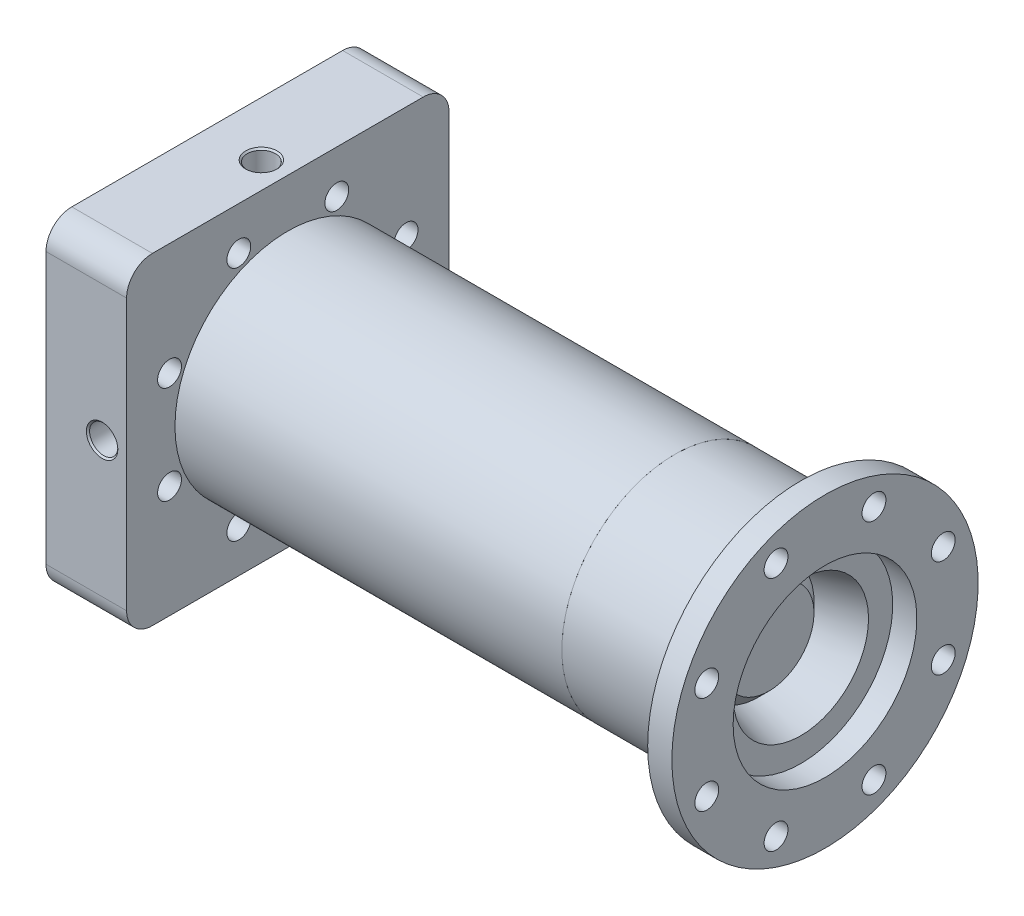
from build123d import *

# Parameters (mm, degrees)
FILLET1_R               = 1.27
CUT_EXTRUDE1_REACH      = 246.555
SKETCH2_R               = 3.81
CIRPATTERN1_COUNT       = 8
SKETCH4_R               = 63.5
BOSS_EXTRUDE1_DEPTH     = 31.75
SKETCH11_W              = 127
SKETCH11_H              = 127
SKETCH11_R              = 63.5
BOSS_EXTRUDE2_DEPTH     = 31.75
SKETCH12_R              = 24.13
CUT_EXTRUDE4_DEPTH      = 16.51
CUT_EXTRUDE5_START      = -39.450428
SKETCH13_R              = 1.9685
CUT_EXTRUDE5_DEPTH      = 39.450428
CHAMFER1_SIZE           = 4.572
FILLET2_R               = 0.889
FILLET3_R               = 0.508
CUT_EXTRUDE9_REACH      = 270.149
CUT_EXTRUDE9_END_RADIUS = 24.13
SKETCH31_R              = 1.5875
SKETCH33_R              = 44.45
SKETCH33_R_2            = 34.925
BOSS_EXTRUDE4_DEPTH     = 152.4
FILLET5_R               = 1.27
FILLET6_R               = 10.16
SKETCH39_R              = 60.325
SKETCH39_R_2            = 36.195
BOSS_EXTRUDE6_DEPTH     = 9.525
SKETCH40_R              = 4.699
CUT_EXTRUDE13_DEPTH     = 251.487228873
CIRPATTERN3_COUNT       = 8
SKETCH44_R              = 1.7653


with BuildPart() as part:
    # Chamber Revolve → Revolve1 (revolve)
    with BuildSketch(Plane.XY, mode=Mode.PRIVATE) as revolve1_sk:
        with BuildLine():
            Line((227.4696953, 63.5), (227.4696953, 26.67))
            Line((227.4696953, 26.67), (191.916500941, 17.143550283))
            ThreePointArc((191.916500941, 17.143550283), (190.601700192, 17.143550283), (189.463049342, 17.800950658))
            Line((189.463049342, 17.800950658), (173.736, 33.528))
            Line((173.736, 33.528), (0, 33.528))
            Line((0, 33.528), (0, 42.164))
            Line((0, 42.164), (3.8608, 42.164))
            Line((3.8608, 42.164), (3.8608, 48.2346))
            Line((3.8608, 48.2346), (0, 48.2346))
            Line((0, 48.2346), (0, 63.5))
            Line((0, 63.5), (10.16, 63.5))
            Line((10.16, 63.5), (10.16, 47.244))
            Line((10.16, 47.244), (24.13, 47.244))
            Line((24.13, 47.244), (24.13, 63.5))
            Line((24.13, 63.5), (227.4696953, 63.5))
        make_face()
    revolve(revolve1_sk.sketch.rotate(Axis((0, 0, 0), (1, 0, 0)), 90), axis=Axis((0, 0, 0), (1, 0, 0)))

    # Fillet1
    fillet1_edges = [part.edges().sort_by_distance(p)[0] for p in [
        (24.13, 0, -47.244),
        (10.16, 0, -47.244),
    ]]
    fillet(fillet1_edges, radius=FILLET1_R)

    # Sketch2 → Cut-Extrude1 (cut, up to next)
    with BuildSketch(Plane.ZY, mode=Mode.PRIVATE) as cut_extrude1_sk1:
        with Locations((-21.773156568, 52.565049882)):
            Circle(SKETCH2_R)
    cut_extrude1_tool1 = extrude(cut_extrude1_sk1.sketch, amount=-CUT_EXTRUDE1_REACH, mode=Mode.PRIVATE) & part.part
    cut_extrude1 = cut_extrude1_tool1.solids().sort_by_distance((0, 52.56505, -21.773157))[0]
    add(cut_extrude1, mode=Mode.SUBTRACT)

    # CirPattern1: Cut-Extrude1 ×8 about axis
    cirpattern1_axis = Axis((0, 0, 0), (1, 0, 0))
    for i in range(1, CIRPATTERN1_COUNT):
        add(cut_extrude1.rotate(cirpattern1_axis, i * 360 / CIRPATTERN1_COUNT), mode=Mode.SUBTRACT)

    # Fillet2
    fillet2_edges = [part.edges().sort_by_distance(p)[0] for p in [
        (3.8608, 0, -42.164),
        (3.8608, 0, -48.2346),
    ]]
    fillet(fillet2_edges, radius=FILLET2_R)


with BuildPart() as body_2:
    # Sketch4 → Boss-Extrude1 (new body)
    with BuildSketch(Plane.ZY):
        Circle(SKETCH4_R)
    extrude(amount=BOSS_EXTRUDE1_DEPTH)


with BuildPart() as boss_extrude2_tool:
    # Sketch11 → Boss-Extrude2 (new body)
    with BuildSketch(Plane.ZY.offset(31.75)):
        Rectangle(SKETCH11_W, SKETCH11_H)
        Circle(SKETCH11_R, mode=Mode.SUBTRACT)
    extrude(amount=-BOSS_EXTRUDE2_DEPTH)


with BuildPart() as body_2_1:
    add(body_2.part)


with BuildPart() as body_2_2:
    # Boss-Extrude2: joined with boss_extrude2_tool
    add(body_2_1.part.fuse(boss_extrude2_tool.part, tol=0.00001))


with BuildPart() as boss_extrude2_kept_piece:
    # of the separate pieces the step leaves, the one the design keeps (boss_extrude2_pieces_kept)
    add(body_2_2.part.solids().sort_by_distance((-31.75, -63.5, 63.5))[0])

    # Sketch12 → Cut-Extrude4 (cut)
    with BuildSketch(Plane(origin=(0, 0, 0), x_dir=(0, 0, -1), z_dir=(1, 0, 0))):
        Circle(SKETCH12_R)
    extrude(amount=-CUT_EXTRUDE4_DEPTH, mode=Mode.SUBTRACT)

    # Sketch13 → Cut-Extrude5 (cut)
    with BuildSketch(Plane.XY.offset(63.5).offset(CUT_EXTRUDE5_START)):
        with Locations((-9.652, 0)):
            Circle(SKETCH13_R)
    cut_extrude5 = extrude(amount=CUT_EXTRUDE5_DEPTH, mode=Mode.SUBTRACT)

    # Chamfer1
    chamfer1_edges = [boss_extrude2_kept_piece.edges().sort_by_distance(p)[0] for p in [
        (0, 0, 24.13),
    ]]
    chamfer(chamfer1_edges, length=CHAMFER1_SIZE)

    # Sketch20 → 7_16 _0.4375_ Diameter Hole1 (revolve, cut)
    with BuildSketch(Plane(origin=(-9.652, 0, 63.5), x_dir=(0, -1, 0), z_dir=(1, 0, 0))):
        Polygon((0, 0), (0, 22.388531814), (5.55625, 19.05), (5.55625, 0.635), (6.19125, 0), align=None)
    f_7_16_0_4375_diameter_hole1 = revolve(axis=Axis((-9.652, 0, 69.85), (0, 0, -1)), mode=Mode.SUBTRACT)

    # Mirror1: Cut-Extrude5, 7_16 _0.4375_ Diameter Hole1 across plane
    add(cut_extrude5.mirror(Plane.XY), mode=Mode.SUBTRACT)
    add(f_7_16_0_4375_diameter_hole1.mirror(Plane.XY), mode=Mode.SUBTRACT)

    # Sketch23 → Ø6.7 (6.7) Diameter Hole1 (revolve, cut)
    with BuildSketch(Plane(origin=(-31.75, -33.02, 0), x_dir=(0, 0, 1), z_dir=(0, 1, 0))):
        Polygon((0, 0), (0, 15.220883074), (3.35, 13.208), (3.35, 0.4), (3.75, 0), align=None)
    f_6_7_6_7_diameter_hole1 = revolve(axis=Axis((-38.1, -33.02, 0), (1, 0, 0)), mode=Mode.SUBTRACT)

    # Mirror2: Ø6.7 (6.7) Diameter Hole1 across plane
    add(f_6_7_6_7_diameter_hole1.mirror(Plane.ZX), mode=Mode.SUBTRACT)

    # Sketch24 → Cut-Revolve1 (revolve, cut)
    with BuildSketch(Plane(origin=(0, 0, 0), x_dir=(1, 0, 0), z_dir=(0, 1, 0))):
        with BuildLine():
            Line((-31.75, 7.1374), (-30.958106371, 5.7658))
            Line((-30.958106371, 5.7658), (-29.845, 5.7658))
            ThreePointArc((-29.845, 5.7658), (-29.650596816, 5.727130803), (-29.485789755, 5.617010245))
            Line((-29.485789755, 5.617010245), (-28.73287951, 4.8641))
            Line((-28.73287951, 4.8641), (-16.51, 4.8641))
            Line((-16.51, 4.8641), (-16.51, 0))
            Line((-16.51, 0), (-31.75, 0))
            Line((-31.75, 0), (-31.75, 7.1374))
        make_face()
    revolve(axis=Axis((227.4696953, 0, 0), (-1, 0, 0)), mode=Mode.SUBTRACT)

    # Fillet3
    fillet3_edges = [boss_extrude2_kept_piece.edges().sort_by_distance(p)[0] for p in [
        (-30.958106371, 0, 5.7658),
    ]]
    fillet(fillet3_edges, radius=FILLET3_R)

    # Sketch30 → 7_16 _0.4375_ Diameter Hole2 (revolve, cut)
    with BuildSketch(Plane(origin=(-10.414, -63.5, 0), x_dir=(0, 0, -1), z_dir=(1, 0, 0))):
        Polygon((0, 0), (0, 22.388531814), (5.55625, 19.05), (5.55625, 0.635), (6.19125, 0), align=None)
    f_7_16_0_4375_diameter_hole2 = revolve(axis=Axis((-10.414, -69.85, 0), (0, 1, 0)), mode=Mode.SUBTRACT)

    # Cut-Extrude9: up to this cylinder (the profile starts outside it)
    cut_extrude9_end = Plane(origin=(-10.414, 0, 0), z_dir=(1, 0, 0)) * Cylinder(CUT_EXTRUDE9_END_RADIUS, 589.558, mode=Mode.PRIVATE)
    # Sketch31 → Cut-Extrude9 (cut, up to the surface)
    with BuildSketch(Plane.XZ.offset(63.5), mode=Mode.PRIVATE) as cut_extrude9_sk1:
        with Locations(Location((-10.414, 0, 0), (0, 0, 270))):
            Circle(SKETCH31_R)
    cut_extrude9_tool1 = extrude(cut_extrude9_sk1.sketch, amount=-CUT_EXTRUDE9_REACH, mode=Mode.PRIVATE) - cut_extrude9_end
    cut_extrude9 = cut_extrude9_tool1.solids().sort_by_distance((-10.414, -63.5, 0))[0]
    add(cut_extrude9, mode=Mode.SUBTRACT)

    # Mirror3: 7_16 _0.4375_ Diameter Hole2, Cut-Extrude9 across plane
    add(f_7_16_0_4375_diameter_hole2.mirror(Plane.ZX), mode=Mode.SUBTRACT)
    add(cut_extrude9.mirror(Plane.ZX), mode=Mode.SUBTRACT)

    # Fillet6
    fillet6_edges = [boss_extrude2_kept_piece.edges().sort_by_distance(p)[0] for p in [
        (-15.875, -63.5, 63.5),
        (-15.875, 63.5, 63.5),
        (-15.875, -63.5, -63.5),
        (-15.875, 63.5, -63.5),
    ]]
    fillet(fillet6_edges, radius=FILLET6_R)


with BuildPart() as body_3:
    # Sketch21 → Revolve2 (revolve)
    with BuildSketch(Plane(origin=(0, 0, 0), x_dir=(1, 0, 0), z_dir=(0, 1, 0))):
        Polygon((0, 33.528), (173.736, 33.528), (189.463049342, 17.800950658), (189.463049342, 0), (0, 0), align=None)
    revolve(axis=Axis((189.463049342, 0, 0), (1, 0, 0)))


with BuildPart() as body_3_2:
    # Sketch33 → Boss-Extrude4 (new body)
    with BuildSketch(Plane(origin=(0, 0, 0), x_dir=(0, 0, -1), z_dir=(1, 0, 0))):
        with Locations(Location((0, 0, 0), (0, 0, 180))):
            Circle(SKETCH33_R)
        with Locations(Location((0, 0, 0), (0, 0, 180))):
            Circle(SKETCH33_R_2, mode=Mode.SUBTRACT)
    extrude(amount=BOSS_EXTRUDE4_DEPTH)


with BuildPart() as body_4:
    # Sketch34 → Revolve3 (revolve)
    with BuildSketch(Plane.XY, mode=Mode.PRIVATE) as revolve3_sk:
        Polygon((152.4, 44.45), (152.4, 34.925), (165.116469101, 16.764), (202.086164401, 26.67), (202.086164401, 44.45), align=None)
    revolve(revolve3_sk.sketch.rotate(Axis((152.4, 0, 0), (-1, 0, 0)), 90), axis=Axis((152.4, 0, 0), (-1, 0, 0)))

    # Fillet5
    fillet5_edges = [body_4.edges().sort_by_distance(p)[0] for p in [
        (165.116469101, 0, 16.764),
    ]]
    fillet(fillet5_edges, radius=FILLET5_R)

    # Sketch45 → Cut-Revolve3 (revolve, cut)
    with BuildSketch(Plane.XY, mode=Mode.PRIVATE) as cut_revolve3_sk:
        with BuildLine():
            Line((152.4, 41.4274), (154.5336, 41.4274))
            ThreePointArc((154.5336, 41.4274), (154.892810245, 41.278610245), (155.0416, 40.9194))
            Line((155.0416, 40.9194), (155.0416, 37.846))
            ThreePointArc((155.0416, 37.846), (154.892810245, 37.486789755), (154.5336, 37.338))
            Line((154.5336, 37.338), (152.4, 37.338))
            Line((152.4, 37.338), (152.4, 41.4274))
        make_face()
    revolve(cut_revolve3_sk.sketch.rotate(Axis((0, 0, 0), (1, 0, 0)), 90), axis=Axis((0, 0, 0), (1, 0, 0)), mode=Mode.SUBTRACT)


with BuildPart() as body_5:
    # Sketch39 → Boss-Extrude6 (new body)
    with BuildSketch(Plane(origin=(202.086164401, 0, 0), x_dir=(0, 0, -1), z_dir=(1, 0, 0))):
        with Locations(Location((0, 0, 0), (0, 0, 180))):
            Circle(SKETCH39_R)
        with Locations(Location((0, 0, 0), (0, 0, 180))):
            Circle(SKETCH39_R_2, mode=Mode.SUBTRACT)
    extrude(amount=BOSS_EXTRUDE6_DEPTH)


with BuildPart() as cut_extrude13_tool:
    # Sketch40 → Cut-Extrude13 (new, symmetric)
    with BuildSketch(Plane.ZY.offset(-202.086164401)):
        with Locations(Location((-19.294515976, 46.58108215, 0), (0, 0, 180))):
            Circle(SKETCH40_R)
    cut_extrude13 = extrude(amount=CUT_EXTRUDE13_DEPTH, both=True)


with BuildPart() as boss_extrude2_kept_piece_1:
    add(boss_extrude2_kept_piece.part)

    # Cut-Extrude13: cut by cut_extrude13_tool
    add(cut_extrude13_tool.part, mode=Mode.SUBTRACT)


with BuildPart() as body_5_1:
    add(body_5.part)

    # Cut-Extrude13: cut by cut_extrude13_tool
    add(cut_extrude13_tool.part, mode=Mode.SUBTRACT)


with BuildPart() as cirpattern3_tool:
    # CirPattern3: Cut-Extrude13 ×8 about axis
    cirpattern3_axis = Axis((0, 0, 0), (1, 0, 0))
    for i in range(1, CIRPATTERN3_COUNT):
        add(cut_extrude13.rotate(cirpattern3_axis, i * 360 / CIRPATTERN3_COUNT))


with BuildPart() as boss_extrude2_kept_piece_2:
    add(boss_extrude2_kept_piece_1.part)

    # CirPattern3: cut by cirpattern3_tool
    add(cirpattern3_tool.part, mode=Mode.SUBTRACT)

    # Sketch41 → Cut-Revolve2 (revolve, cut)
    with BuildSketch(Plane.XY, mode=Mode.PRIVATE) as cut_revolve2_sk:
        with BuildLine():
            Line((0, 37.338), (-2.1844, 37.338))
            ThreePointArc((-2.1844, 37.338), (-2.50768922, 37.47191078), (-2.6416, 37.7952))
            Line((-2.6416, 37.7952), (-2.6416, 40.9702))
            ThreePointArc((-2.6416, 40.9702), (-2.50768922, 41.29348922), (-2.1844, 41.4274))
            Line((-2.1844, 41.4274), (0, 41.4274))
            Line((0, 41.4274), (0, 37.338))
        make_face()
    revolve(cut_revolve2_sk.sketch.rotate(Axis((0, 0, 0), (1, 0, 0)), 90), axis=Axis((0, 0, 0), (1, 0, 0)), mode=Mode.SUBTRACT)


with BuildPart() as body_5_2:
    add(body_5_1.part)

    # CirPattern3: cut by cirpattern3_tool
    add(cirpattern3_tool.part, mode=Mode.SUBTRACT)


with BuildPart() as body_6:
    # Sketch44 → Revolve4 (revolve)
    with BuildSketch(Plane.XY, mode=Mode.PRIVATE) as revolve4_sk:
        with Locations((-0.8763, 39.6621)):
            Circle(SKETCH44_R)
    revolve(revolve4_sk.sketch.rotate(Axis((0, 0, 0), (1, 0, 0)), 90), axis=Axis((0, 0, 0), (1, 0, 0)))


with BuildPart() as body_7:
    # Mirror9: mirrored copy
    add(body_6.part.mirror(Plane(origin=(76.2, 0, 0), x_dir=(0, 0, 1), z_dir=(1, 0, 0))))


solid = Compound([body_3.part, body_3_2.part, body_4.part, boss_extrude2_kept_piece_2.part, body_5_2.part, body_6.part, body_7.part])
